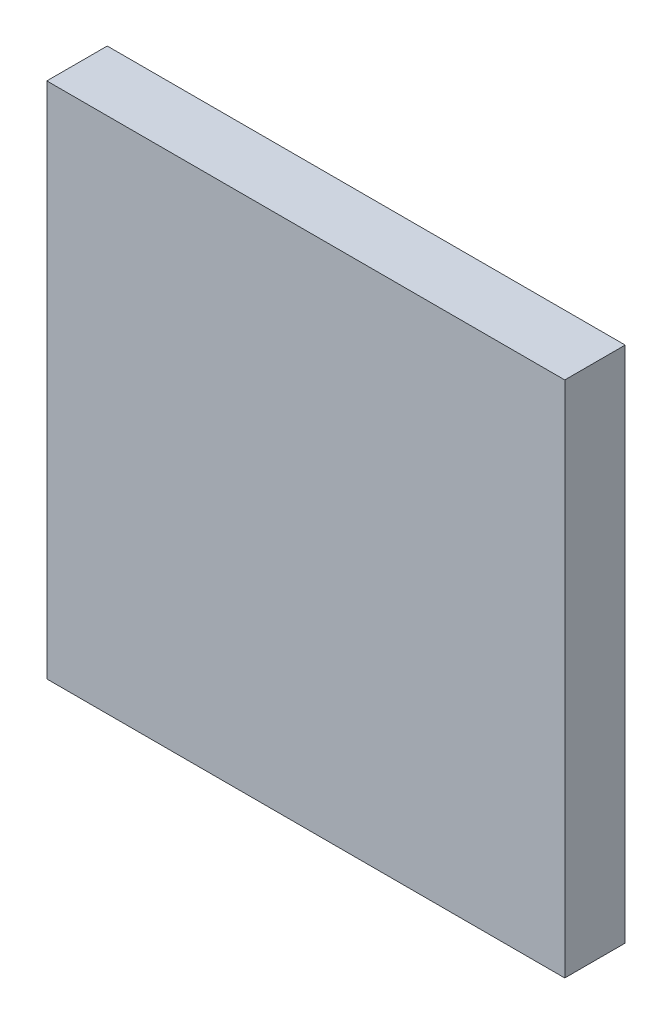
from build123d import *

# Parameters (mm, degrees)
SKETCH1_W           = 12
SKETCH1_H           = 12
BOSS_EXTRUDE1_DEPTH = 1.4


with BuildPart() as part:
    # Sketch1 → Boss-Extrude1 (new body)
    with BuildSketch(Plane.XY):
        Rectangle(SKETCH1_W, SKETCH1_H)
    extrude(amount=BOSS_EXTRUDE1_DEPTH)


solid = part.part
